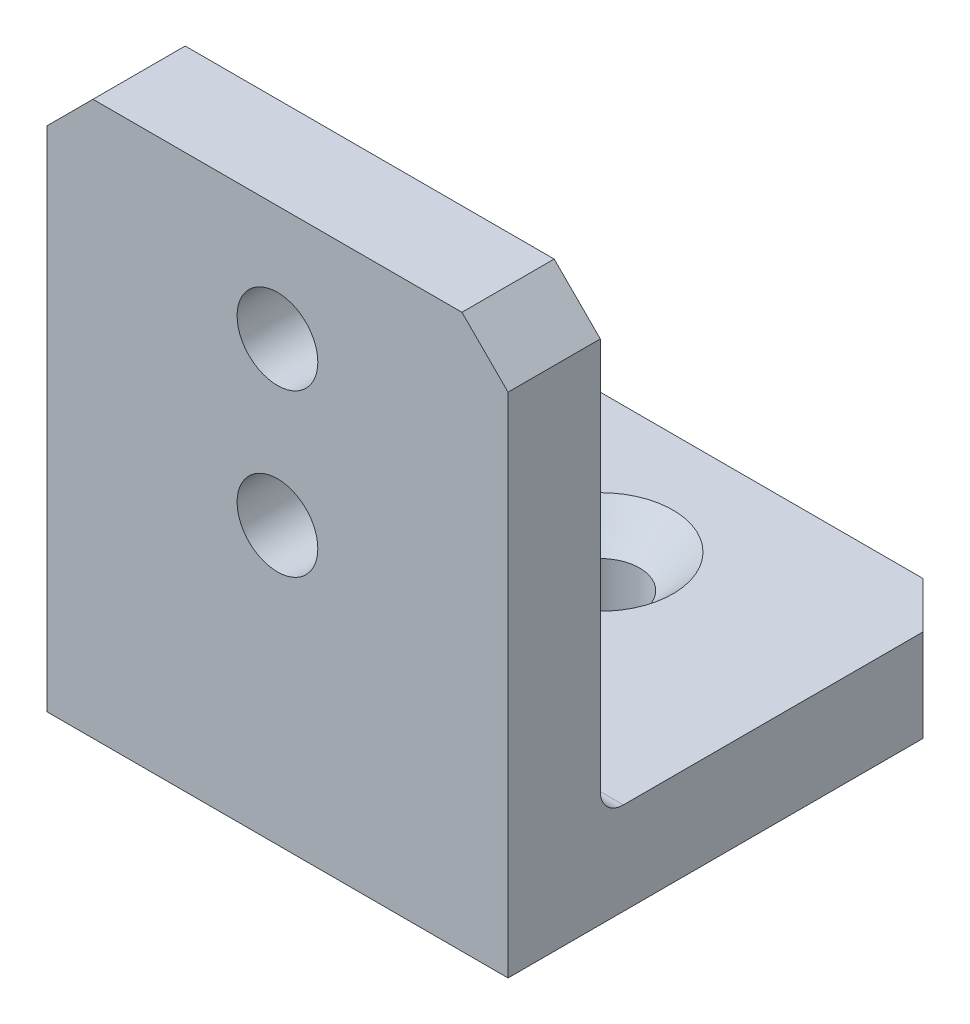
from build123d import *

# Parameters (mm, degrees)
SCHIZZO1_W                                      = 20
SCHIZZO1_H                                      = 4
ESTRUSIONE_ESTRUSIONE1_DEPTH                    = 20
SCHIZZO2_W                                      = 20
SCHIZZO2_H                                      = 4
ESTRUSIONE_ESTRUSIONE2_DEPTH                    = 20
TAGLIO_ESTRUSIONE2_REACH                        = 6
SCHIZZO7_R                                      = 1.75
RACCORDO1_R                                     = 1
SMUSSO1_SIZE                                    = 2
SMUSSO3_SIZE                                    = 2
CSK_FOR_M3_OVAL_HEAD_MACHINE_SCREW1_D           = 3.4
CSK_FOR_M3_OVAL_HEAD_MACHINE_SCREW1_CSINK_D     = 6.3
CSK_FOR_M3_OVAL_HEAD_MACHINE_SCREW1_CSINK_ANGLE = 90


with BuildPart() as part:
    # Schizzo1 → Estrusione-Estrusione1 (new body)
    with BuildSketch(Plane.XY):
        with Locations((10, 2)):
            Rectangle(SCHIZZO1_W, SCHIZZO1_H)
    extrude(amount=ESTRUSIONE_ESTRUSIONE1_DEPTH)

    # Schizzo2 → Estrusione-Estrusione2 (add)
    with BuildSketch(Plane(origin=(0, 4, 0), x_dir=(1, 0, 0), z_dir=(0, 1, 0))):
        with Locations((10, -18)):
            Rectangle(SCHIZZO2_W, SCHIZZO2_H)
    extrude(amount=ESTRUSIONE_ESTRUSIONE2_DEPTH)

    # Schizzo7 → Taglio-Estrusione2 (cut, up to next)
    with BuildSketch(Plane(origin=(0, 0, 16), x_dir=(-1, 0, 0), z_dir=(0, 0, -1)), mode=Mode.PRIVATE) as taglio_estrusione2_sk1:
        with Locations((-10, 19)):
            Circle(SCHIZZO7_R)
    taglio_estrusione2_tool1 = extrude(taglio_estrusione2_sk1.sketch, amount=-TAGLIO_ESTRUSIONE2_REACH, mode=Mode.PRIVATE) & part.part
    add(taglio_estrusione2_tool1.solids().sort_by_distance((10, 19, 16))[0], mode=Mode.SUBTRACT)
    # Schizzo7 → Taglio-Estrusione2 (cut, up to next)
    with BuildSketch(Plane(origin=(0, 0, 16), x_dir=(-1, 0, 0), z_dir=(0, 0, -1)), mode=Mode.PRIVATE) as taglio_estrusione2_sk2:
        with Locations((-10, 12)):
            Circle(SCHIZZO7_R)
    taglio_estrusione2_tool2 = extrude(taglio_estrusione2_sk2.sketch, amount=-TAGLIO_ESTRUSIONE2_REACH, mode=Mode.PRIVATE) & part.part
    add(taglio_estrusione2_tool2.solids().sort_by_distance((10, 12, 16))[0], mode=Mode.SUBTRACT)

    # Raccordo1
    raccordo1_edges = [part.edges().sort_by_distance(p)[0] for p in [
        (10, 4, 16),
    ]]
    fillet(raccordo1_edges, radius=RACCORDO1_R)

    # Smusso1
    smusso1_edges = [part.edges().sort_by_distance(p)[0] for p in [
        (0, 24, 18),
        (20, 24, 18),
    ]]
    chamfer(smusso1_edges, length=SMUSSO1_SIZE)

    # Smusso3
    smusso3_edges = [part.edges().sort_by_distance(p)[0] for p in [
        (20, 2, 0),
        (0, 2, 0),
    ]]
    chamfer(smusso3_edges, length=SMUSSO3_SIZE)

    # CSK for M3 Oval Head Machine Screw1 (through all)
    with Locations(Plane(origin=(10, 4, 6), x_dir=(0, 0, 1), z_dir=(0, 1, 0))):
        with Locations((0, 0)):
            CounterSinkHole(CSK_FOR_M3_OVAL_HEAD_MACHINE_SCREW1_D / 2, CSK_FOR_M3_OVAL_HEAD_MACHINE_SCREW1_CSINK_D / 2, counter_sink_angle=CSK_FOR_M3_OVAL_HEAD_MACHINE_SCREW1_CSINK_ANGLE)


solid = part.part
